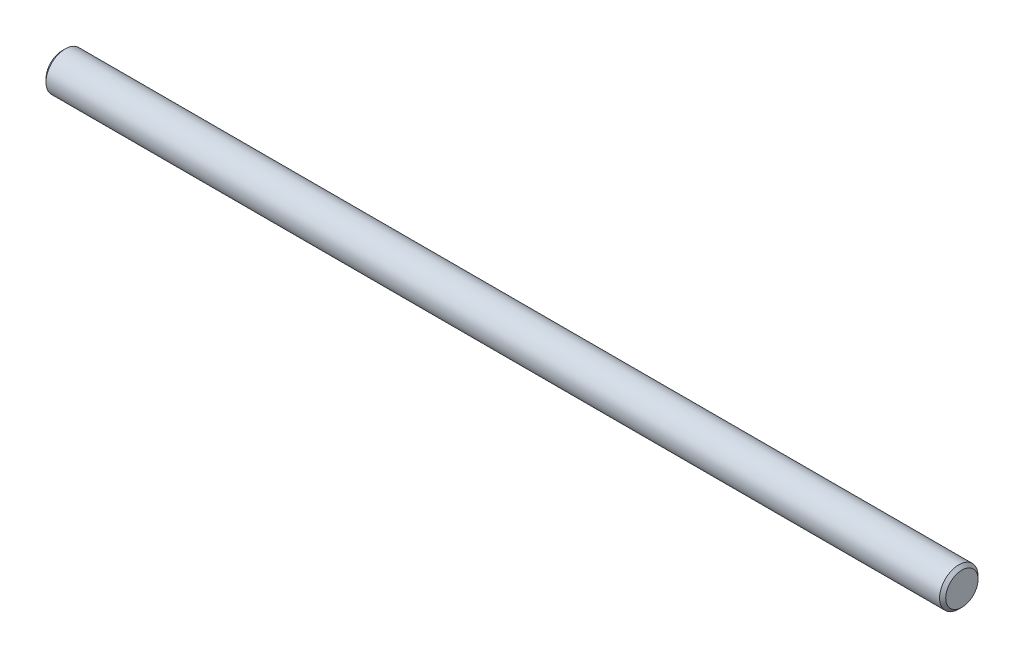
from build123d import *

# Parameters (mm, degrees)
SKETCH1_W     = 117
SKETCH1_H     = 2.5
CHAMFER1_SIZE = 0.4


with BuildPart() as part:
    # Sketch1 → Revolve1 (revolve)
    with BuildSketch(Plane.XY):
        with Locations((58.5, 1.25)):
            Rectangle(SKETCH1_W, SKETCH1_H)
    revolve(axis=Axis((0, 0, 0), (1, 0, 0)))

    # Chamfer1
    chamfer1_edges = [part.edges().sort_by_distance(p)[0] for p in [
        (117, -2.5, 0),
        (0, -2.5, 0),
    ]]
    chamfer(chamfer1_edges, length=CHAMFER1_SIZE)


solid = part.part
